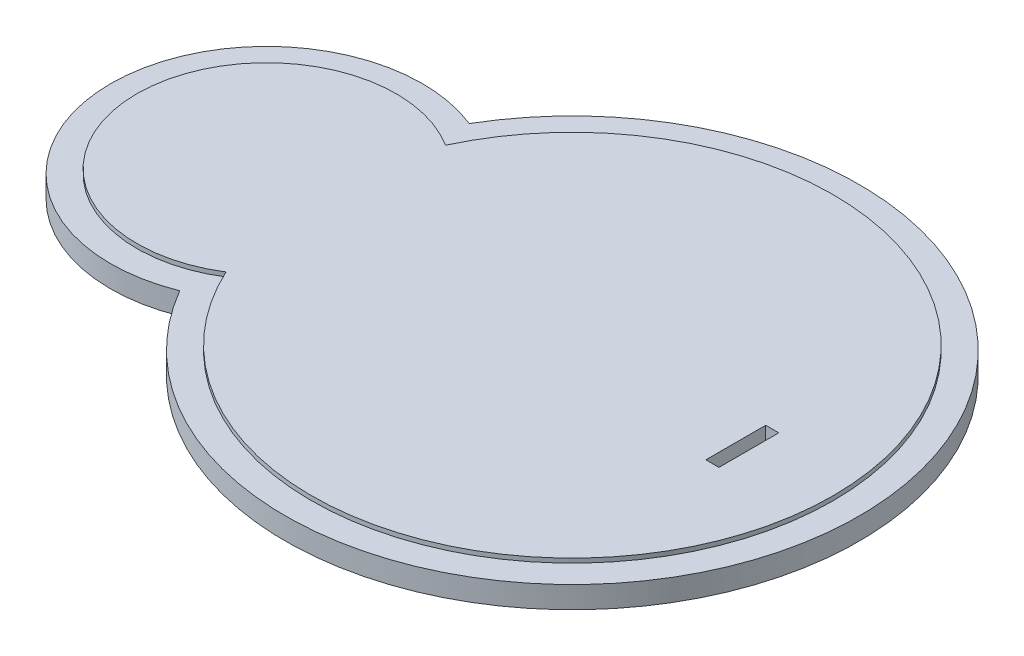
from build123d import *

# Parameters (mm, degrees)
BOSS_EXTRUDE1_DEPTH = 6
BOSS_EXTRUDE2_DEPTH = 5
SKETCH2_W           = 3
SKETCH2_H           = 13.7
CUT_EXTRUDE1_DEPTH  = 125.599277687


with BuildPart() as part:
    # Sketch1 → Boss-Extrude1 (new body)
    with BuildSketch(Plane(origin=(0, 0, 0), x_dir=(1, 0, 0), z_dir=(0, 1, 0))):
        with BuildLine():
            ThreePointArc((-54.157142857, -25.121581908), (59.7, 0), (-54.157142857, 25.121581908))
            ThreePointArc((-54.157142857, 25.121581908), (-99.7, 0), (-54.157142857, -25.121581908))
        make_face()
    extrude(amount=BOSS_EXTRUDE1_DEPTH)

    # Sketch1_3 → Boss-Extrude2 (add)
    with BuildSketch(Plane(origin=(0, 0, 0), x_dir=(1, 0, 0), z_dir=(0, 1, 0))):
        with BuildLine():
            ThreePointArc((-56.728571429, -33.141502435), (65.7, 0), (-56.728571429, 33.141502435))
            ThreePointArc((-56.728571429, 33.141502435), (-105.7, 0), (-56.728571429, -33.141502435))
        make_face()
        with BuildLine():
            ThreePointArc((-54.157142857, -25.121581908), (59.7, 0), (-54.157142857, 25.121581908))
            ThreePointArc((-54.157142857, 25.121581908), (-99.7, 0), (-54.157142857, -25.121581908))
        make_face(mode=Mode.SUBTRACT)
    extrude(amount=BOSS_EXTRUDE2_DEPTH)

    # Sketch2 → Cut-Extrude1 (cut, through all)
    with BuildSketch(Plane(origin=(0, 6, 0), x_dir=(1, 0, 0), z_dir=(0, 1, 0))):
        with Locations((39.508087625, -0.596031436)):
            Rectangle(SKETCH2_W, SKETCH2_H)
    extrude(amount=-CUT_EXTRUDE1_DEPTH, mode=Mode.SUBTRACT)


solid = part.part
